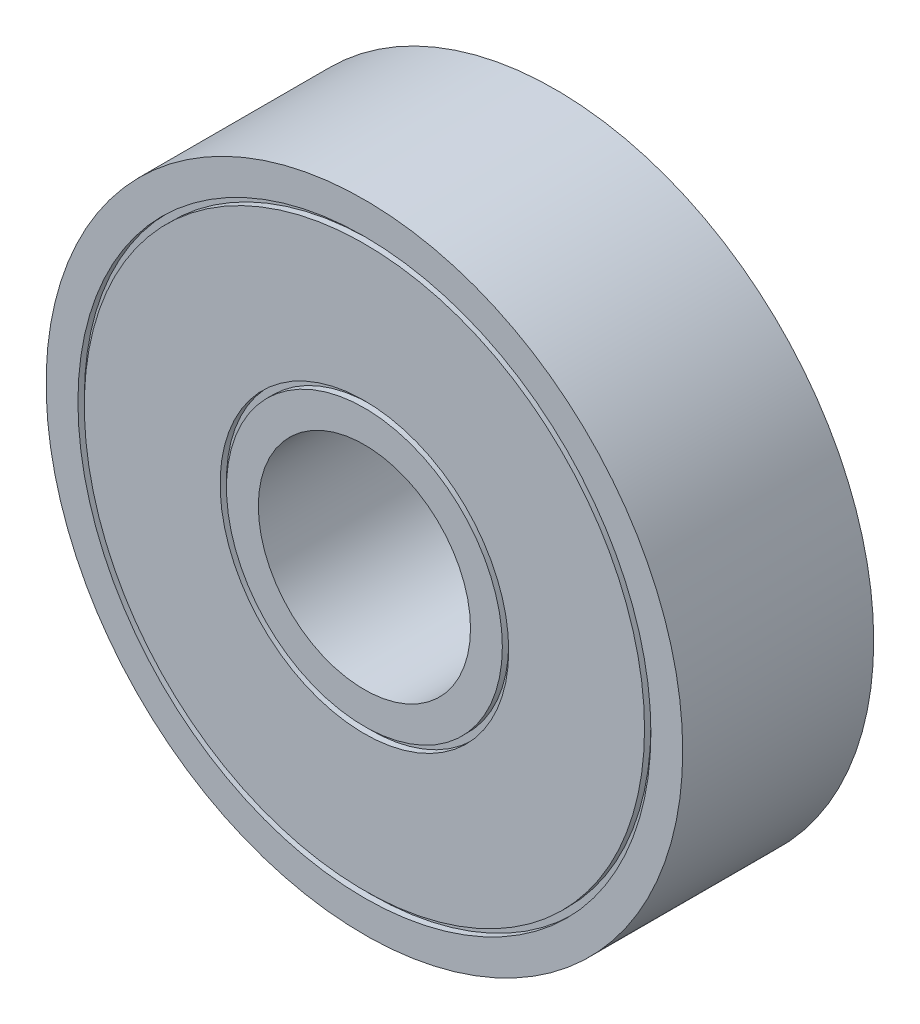
from build123d import *

# Parameters (mm, degrees)
CROQUIS1_R              = 15
CROQUIS1_R_2            = 5
SALIENTE_EXTRUIR1_DEPTH = 9
CROQUIS2_R              = 13.5
CROQUIS2_R_2            = 13.2
CROQUIS2_R_3            = 6.8
CROQUIS2_R_4            = 6.5
CORTAR_EXTRUIR1_DEPTH   = 0.3


with BuildPart() as part:
    # Croquis1 → Saliente-Extruir1 (new body)
    with BuildSketch(Plane.XY):
        Circle(CROQUIS1_R)
        Circle(CROQUIS1_R_2, mode=Mode.SUBTRACT)
    extrude(amount=SALIENTE_EXTRUIR1_DEPTH)

    # Croquis2 → Cortar-Extruir1 (cut)
    with BuildSketch(Plane.XY.offset(9)):
        Circle(CROQUIS2_R)
        Circle(CROQUIS2_R_2, mode=Mode.SUBTRACT)
        Circle(CROQUIS2_R_3)
        Circle(CROQUIS2_R_4, mode=Mode.SUBTRACT)
    cortar_extruir1 = extrude(amount=-CORTAR_EXTRUIR1_DEPTH, mode=Mode.SUBTRACT)

    # Simetría1: Cortar-Extruir1 across plane
    add(cortar_extruir1.mirror(Plane.XY.offset(4.5)), mode=Mode.SUBTRACT)


solid = part.part
